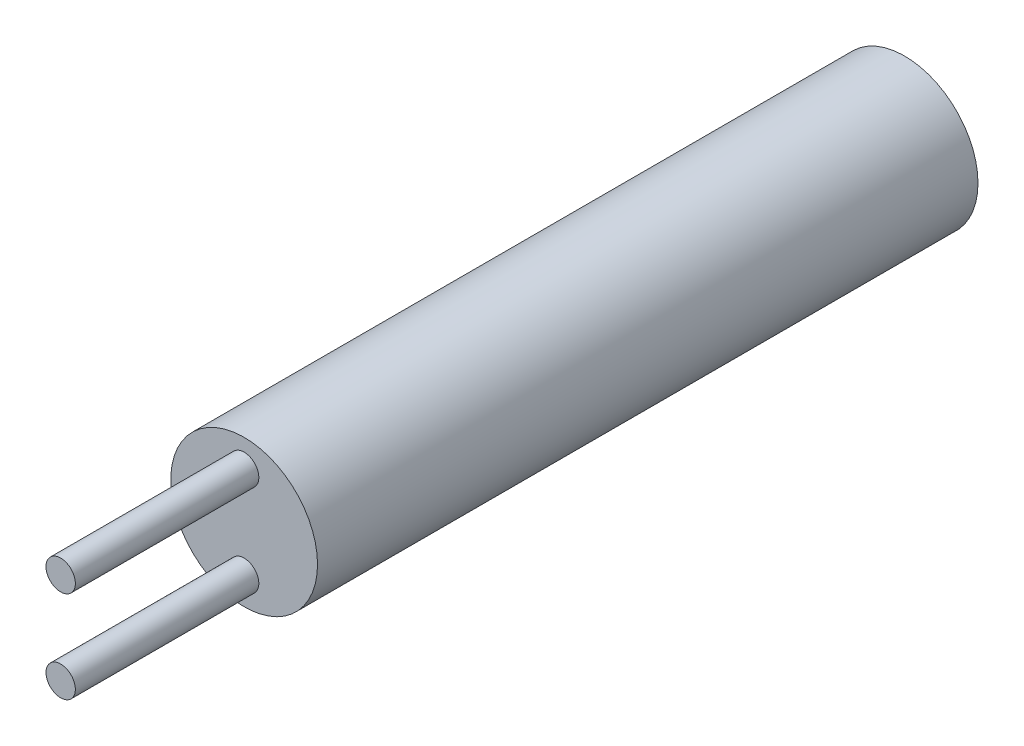
from build123d import *

# Parameters (mm, degrees)
SKETCH1_R           = 2
BOSS_EXTRUDE1_DEPTH = 18
SKETCH2_R           = 0.4
BOSS_EXTRUDE2_DEPTH = 5


with BuildPart() as part:
    # Sketch1 → Boss-Extrude1 (new body)
    with BuildSketch(Plane.XY):
        Circle(SKETCH1_R)
    extrude(amount=BOSS_EXTRUDE1_DEPTH)

    # Sketch2 → Boss-Extrude2 (add)
    with BuildSketch(Plane.XY.offset(18)):
        with Locations((0, 1.25)):
            Circle(SKETCH2_R)
        with Locations((0, -1.25)):
            Circle(SKETCH2_R)
    extrude(amount=BOSS_EXTRUDE2_DEPTH)


solid = part.part
